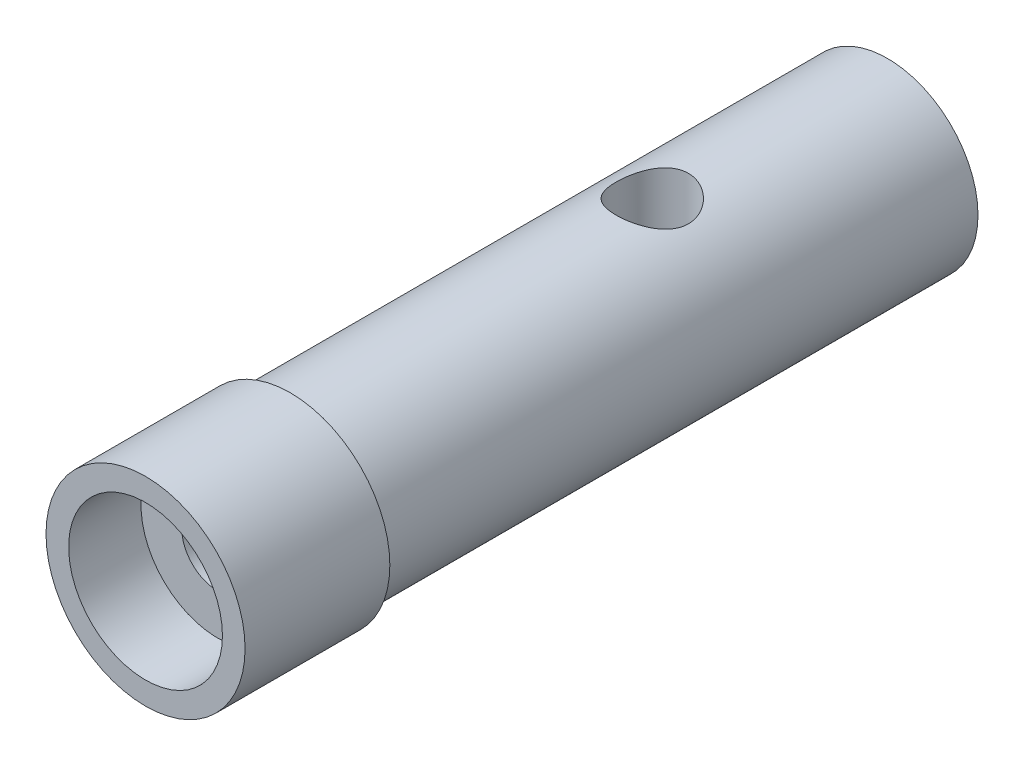
from build123d import *

# Parameters (mm, degrees)
SKETCH1_W                                          = 5.5
SKETCH1_H                                          = 8
SKETCH2_R                                          = 5
BOSS_EXTRUDE1_DEPTH                                = 33
CBORE_FOR_M3_5_HEX_HEAD_MACHINE_SCREW1_D           = 4
CBORE_FOR_M3_5_HEX_HEAD_MACHINE_SCREW1_DEPTH       = 14
CBORE_FOR_M3_5_HEX_HEAD_MACHINE_SCREW1_CBORE_D     = 8.5
CBORE_FOR_M3_5_HEX_HEAD_MACHINE_SCREW1_CBORE_DEPTH = 4
HOLE1_REACH                                        = 38.626
HOLE1_BORE_R                                       = 1
SKETCH6_R                                          = 2
CUT_EXTRUDE1_DEPTH                                 = 10
SKETCH7_R                                          = 2
CUT_EXTRUDE2_DEPTH                                 = 5


with BuildPart() as part:
    # Sketch1 → Revolve1 (revolve)
    with BuildSketch(Plane(origin=(0, 0, 0), x_dir=(1, 0, 0), z_dir=(0, 1, 0))):
        with Locations((2.75, -4)):
            Rectangle(SKETCH1_W, SKETCH1_H)
    revolve(axis=Axis((0, 0, 0), (0, 0, 1)))

    # Sketch2 → Boss-Extrude1 (add)
    with BuildSketch(Plane(origin=(0, 0, 0), x_dir=(-1, 0, 0), z_dir=(0, 0, -1))):
        Circle(SKETCH2_R)
    extrude(amount=BOSS_EXTRUDE1_DEPTH)

    # CBORE for M3.5 Hex Head Machine Screw1
    with Locations(Plane.XY.offset(8)):
        with Locations((0, 0)):
            CounterBoreHole(CBORE_FOR_M3_5_HEX_HEAD_MACHINE_SCREW1_D / 2, CBORE_FOR_M3_5_HEX_HEAD_MACHINE_SCREW1_CBORE_D / 2, CBORE_FOR_M3_5_HEX_HEAD_MACHINE_SCREW1_CBORE_DEPTH, depth=CBORE_FOR_M3_5_HEX_HEAD_MACHINE_SCREW1_DEPTH)

    # Hole1 bore (on position points) → Hole1 (cut, up to next)
    with BuildSketch(Plane(origin=(-5.5, 0, 1.5), x_dir=(0, -1, 0), z_dir=(-1, 0, 0)), mode=Mode.PRIVATE) as hole1_sk1:
        Circle(HOLE1_BORE_R)
    hole1_tool1 = extrude(hole1_sk1.sketch, amount=-HOLE1_REACH, mode=Mode.PRIVATE) & part.part
    add(hole1_tool1.solids().sort_by_distance((-5.5, 0, 1.5))[0], mode=Mode.SUBTRACT)

    # Sketch6 → Cut-Extrude1 (cut)
    with BuildSketch(Plane(origin=(0, 0, -33), x_dir=(-1, 0, 0), z_dir=(0, 0, -1))):
        with Locations(Location((0, 0, 0), (0, 0, 180))):
            Circle(SKETCH6_R)
    extrude(amount=-CUT_EXTRUDE1_DEPTH, mode=Mode.SUBTRACT)

    # Sketch7 → Cut-Extrude2 (cut)
    with BuildSketch(Plane(origin=(0, 5, 0), x_dir=(1, 0, 0), z_dir=(0, 1, 0))):
        with Locations(Location((0, 20, 0), (0, 0, 270))):
            Circle(SKETCH7_R)
    extrude(amount=-CUT_EXTRUDE2_DEPTH, mode=Mode.SUBTRACT)


solid = part.part
